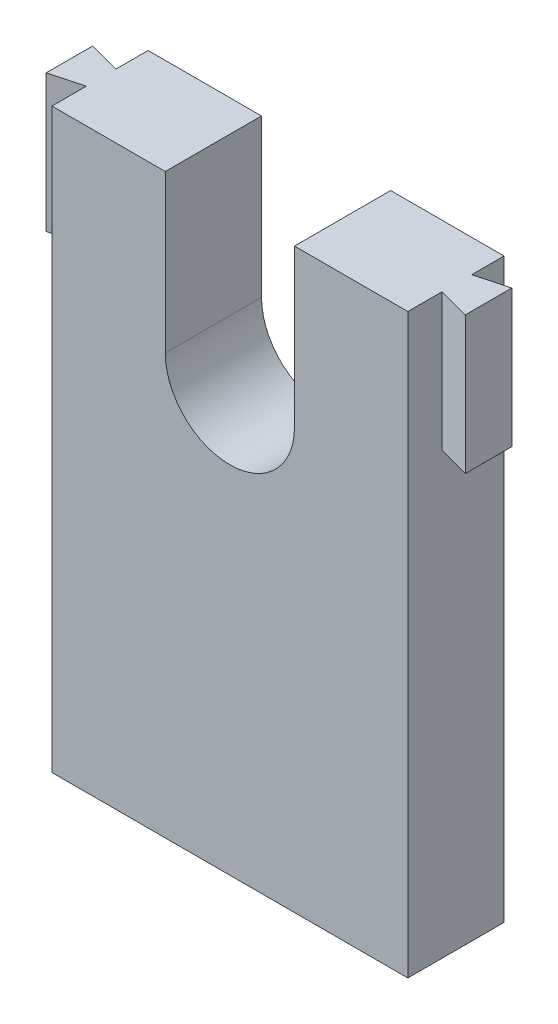
from build123d import *

# Parameters (mm, degrees)
SKETCH1_W           = 25.9
SKETCH1_H           = 30
BOSS_EXTRUDE1_DEPTH = 7
BOSS_EXTRUDE2_DEPTH = 10
CUT_EXTRUDE1_DEPTH  = 10
SKETCH4_W           = 25.9
SKETCH4_H           = 7
BOSS_EXTRUDE3_DEPTH = 12


with BuildPart() as part:
    # Sketch1 → Boss-Extrude1 (new body)
    with BuildSketch(Plane.XY):
        with Locations((-0.908401305, 7.099021207)):
            Rectangle(SKETCH1_W, SKETCH1_H)
    extrude(amount=BOSS_EXTRUDE1_DEPTH)

    # Sketch2 → Boss-Extrude2 (add)
    with BuildSketch(Plane(origin=(0, 22.099021207, 0), x_dir=(1, 0, 0), z_dir=(0, 1, 0))):
        Polygon((-13.858401305, -4.5), (-16.158401305, -5.116283143), (-16.158401305, -1.733716857), (-13.858401305, -2.35), align=None)
        Polygon((12.041598695, -2.35), (14.341598695, -1.733716857), (14.341598695, -5.116283143), (12.041598695, -4.5), align=None)
    extrude(amount=-BOSS_EXTRUDE2_DEPTH)

    # Sketch3 → Cut-Extrude1 (cut)
    with BuildSketch(Plane(origin=(0, 0, 0), x_dir=(-1, 0, 0), z_dir=(0, 0, -1))):
        with BuildLine():
            Line((-3.791598695, 10.666053203), (-3.791598695, 22.099021207))
            Line((-3.791598695, 22.099021207), (5.608401305, 22.099021207))
            Line((5.608401305, 22.099021207), (5.608401305, 10.666053203))
            ThreePointArc((5.608401305, 10.666053203), (0.908401305, 5.966053203), (-3.791598695, 10.666053203))
        make_face()
    extrude(amount=-CUT_EXTRUDE1_DEPTH, mode=Mode.SUBTRACT)

    # Sketch4 → Boss-Extrude3 (add)
    with BuildSketch(Plane.XZ.offset(7.900978793)):
        with Locations((-0.908401305, 3.5)):
            Rectangle(SKETCH4_W, SKETCH4_H)
    extrude(amount=BOSS_EXTRUDE3_DEPTH)


solid = part.part
